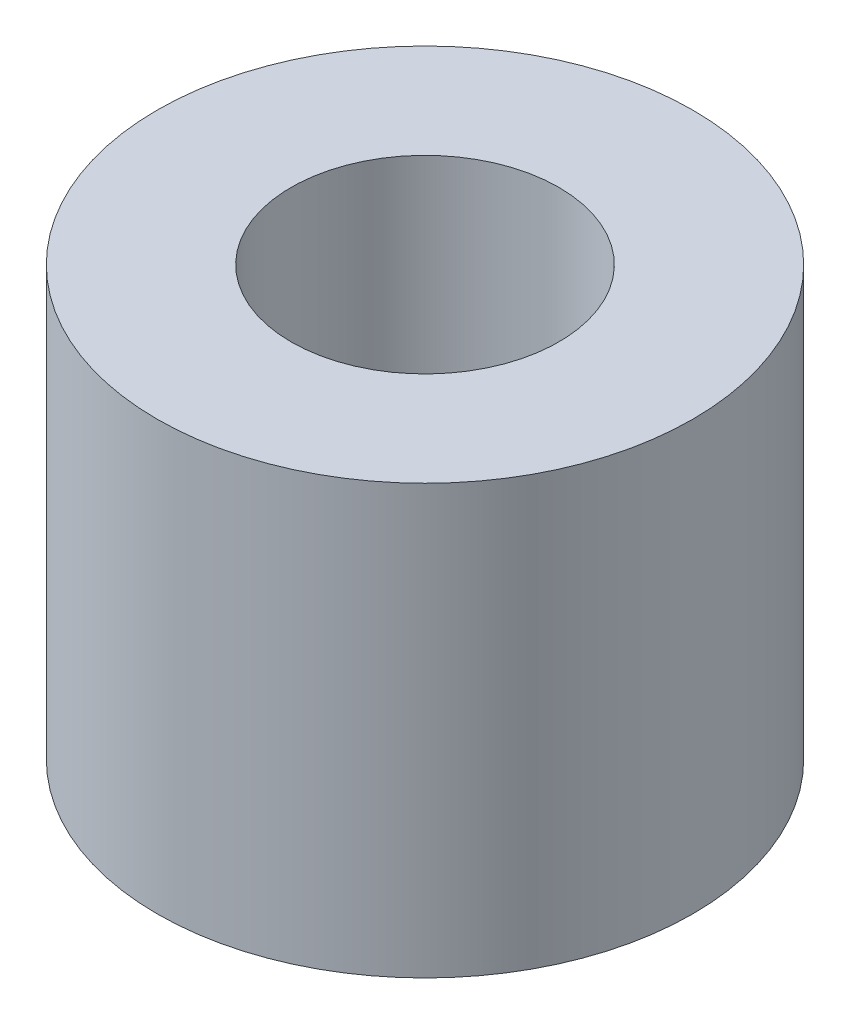
from build123d import *

# Parameters (mm, degrees)
SKETCH1_R                   = 7.9375
BOSS_EXTRUDE1_DEPTH         = 12.7
F_3_8_16_TAPPED_HOLE1_D     = 7.9375
F_3_8_16_TAPPED_HOLE1_DEPTH = 11.176


with BuildPart() as part:
    # Sketch1 → Boss-Extrude1 (new body)
    with BuildSketch(Plane(origin=(0, 0, 0), x_dir=(1, 0, 0), z_dir=(0, 1, 0))):
        Circle(SKETCH1_R)
    extrude(amount=BOSS_EXTRUDE1_DEPTH)

    # 3/8-16 Tapped Hole1
    with Locations(Plane(origin=(0, 12.7, 0), x_dir=(-1, 0, 0), z_dir=(0, 1, 0))):
        with Locations((0, 0)):
            Hole(F_3_8_16_TAPPED_HOLE1_D / 2, depth=F_3_8_16_TAPPED_HOLE1_DEPTH)


solid = part.part
